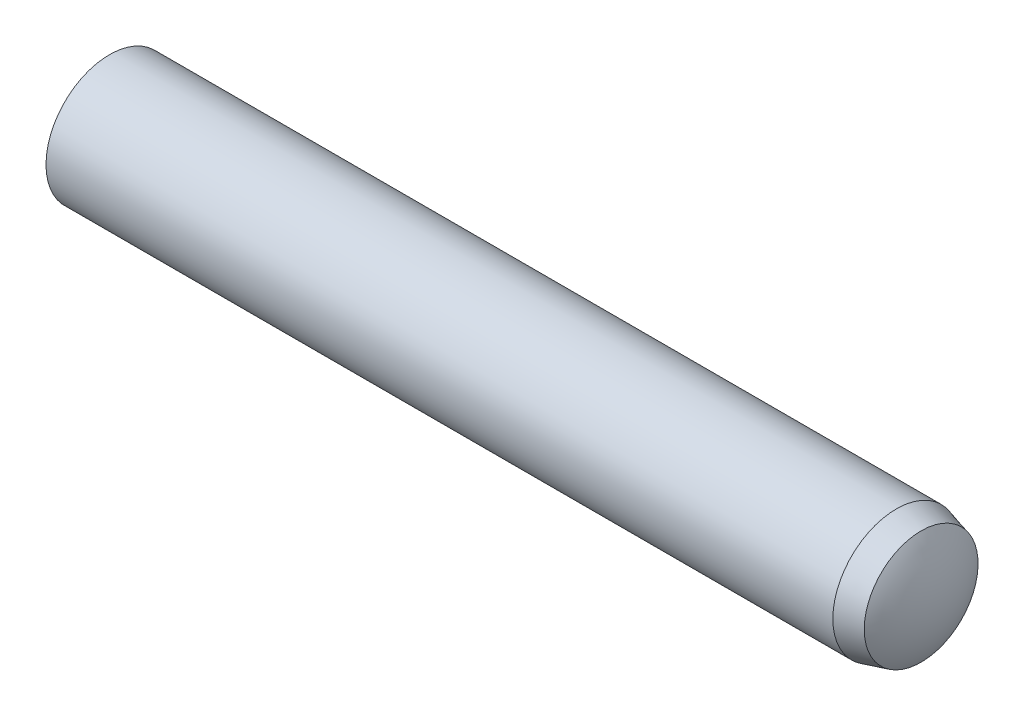
from build123d import *

# Parameters (mm, degrees)
SKETCH2_R           = 3
EXTRUDE1_DEPTH      = 20
EXTRUDE1_DEPTH_BACK = 20


with BuildPart() as part:
    # Sketch2 → Extrude1 (new body, two sides)
    with BuildSketch(Plane(origin=(0, 0, 0), x_dir=(0, 0, -1), z_dir=(1, 0, 0))) as extrude1_sk:
        Circle(SKETCH2_R)
    extrude(amount=EXTRUDE1_DEPTH)
    extrude(extrude1_sk.sketch, amount=-EXTRUDE1_DEPTH_BACK)

    # Sketch5 → Cut-Revolve1 (revolve, cut)
    with BuildSketch(Plane.XY):
        with BuildLine():
            Line((18.05, 3), (18.05, 3.5))
            Line((18.05, 3.5), (20.5, 3.5))
            Line((20.5, 3.5), (20.5, 0))
            Line((20.5, 0), (20, 0))
            ThreePointArc((20, 0), (19.801055079, 1.398720779), (19.22, 2.686499445))
            Line((19.22, 2.686499445), (18.05, 3))
        make_face()
        with BuildLine():
            Line((-19.1, 3), (-19.1, 3.5))
            Line((-19.1, 3.5), (-20.5, 3.5))
            Line((-20.5, 3.5), (-20.5, 0))
            Line((-20.5, 0), (-20, 0))
            ThreePointArc((-20, 0), (-19.770153254, 1.566045976), (-19.1, 3))
        make_face()
    revolve(axis=Axis((-20, 0, 0), (1, 0, 0)), mode=Mode.SUBTRACT)


solid = part.part
